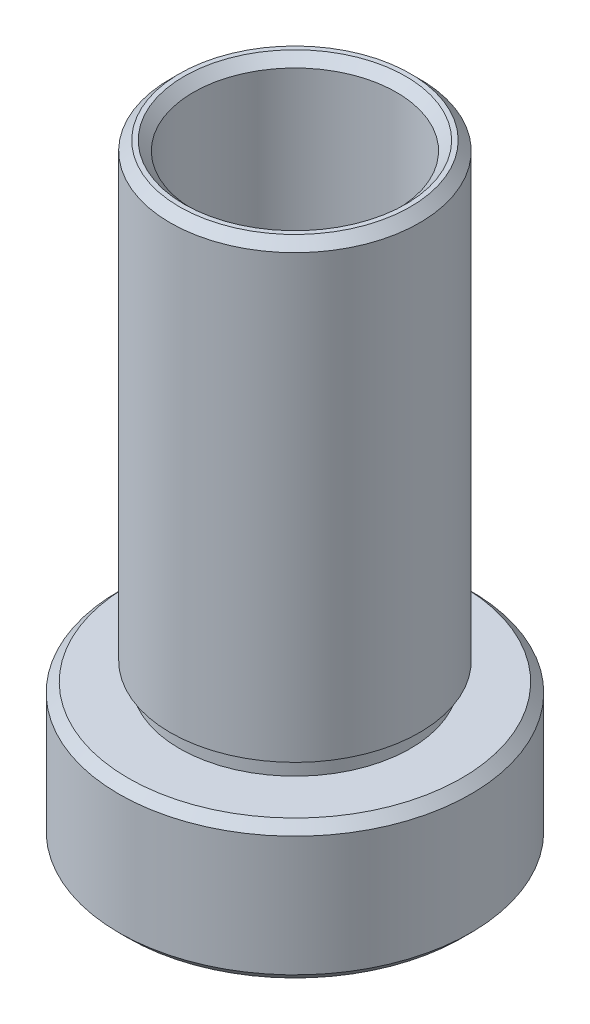
from build123d import *


with BuildPart() as part:
    # 草图1 → 旋转2 (revolve)
    with BuildSketch(Plane.XY, mode=Mode.PRIVATE) as revolve_2_sk:
        Polygon((6, 27.042854175), (6.25, 27.042854175), (6.75, 26.542854175), (6.75, 2.642854175), (6.25, 2.642854175), (6.25, 1.642854175), (9.025, 1.642854175), (9.525, 1.142854175), (9.525, -5.357145825), (9.025, -5.857145825), (8, -5.857145825), (7.5, -5.357145825), (7.5, -1.357145825), (7.6, -1.357145825), (7.6, -0.357145825), (5.5, -0.357145825), (5.5, 26.542854175), align=None)
    revolve(revolve_2_sk.sketch.rotate(Axis((0, 44.598597745, 0), (0, -1, 0)), 90), axis=Axis((0, 44.598597745, 0), (0, -1, 0)))  # turned: the seam where the file's is


solid = part.part
